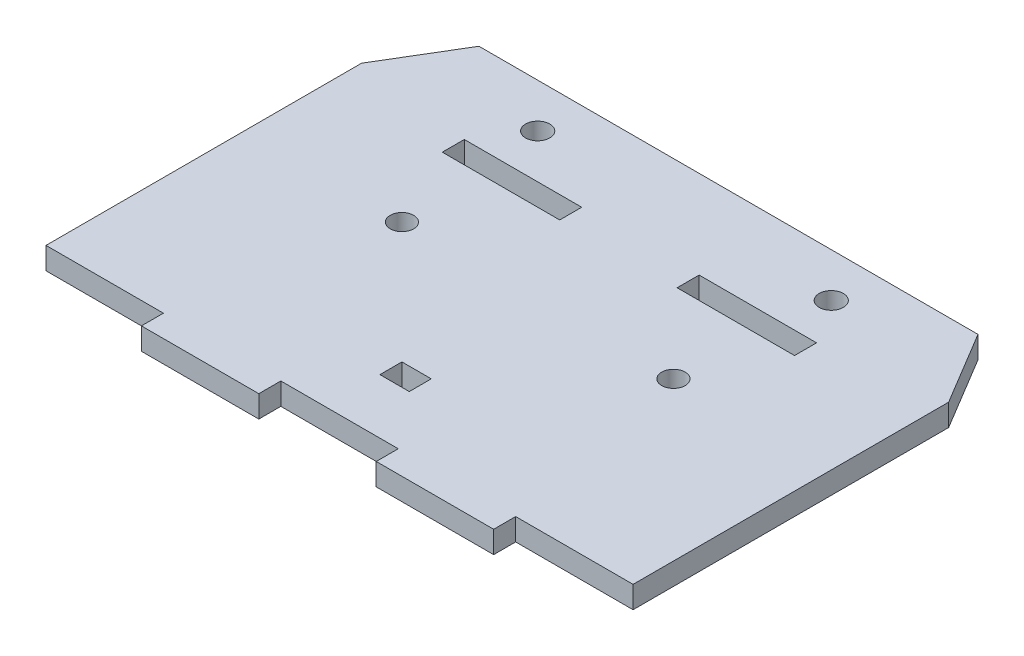
from build123d import *

# Parameters (mm, degrees)
SKETCH1_R           = 1.65
BOSS_EXTRUDE1_DEPTH = 3
SKETCH2_R           = 1.6
SKETCH2_W           = 4
SKETCH2_H           = 3
SKETCH2_W_2         = 16
CUT_EXTRUDE1_DEPTH  = 4


with BuildPart() as part:
    # Sketch1 → Boss-Extrude1 (new body)
    with BuildSketch(Plane(origin=(0, 0, 0), x_dir=(1, 0, 0), z_dir=(0, 1, 0))):
        Polygon((-40, 37), (-34, 47), (34, 47), (40, 37), (40, -6), (24, -6), (24, -9), (8, -9), (8, -6), (-8, -6), (-8, -9), (-24, -9), (-24, -6), (-40, -6), align=None)
        with Locations((-20, 41)):
            Circle(SKETCH1_R, mode=Mode.SUBTRACT)
        with Locations((20, 41.003103662)):
            Circle(SKETCH1_R, mode=Mode.SUBTRACT)
    extrude(amount=BOSS_EXTRUDE1_DEPTH)

    # Sketch2 → Cut-Extrude1 (cut, through all)
    with BuildSketch(Plane(origin=(0, 3, 0), x_dir=(1, 0, 0), z_dir=(0, 1, 0))):
        with Locations((-18.5, 21)):
            Circle(SKETCH2_R)
        with Locations((18.5, 21)):
            Circle(SKETCH2_R)
        with Locations((0, 3)):
            Rectangle(SKETCH2_W, SKETCH2_H)
        with Locations((-16, 33.5)):
            Rectangle(SKETCH2_W_2, SKETCH2_H)
        with Locations((16, 33.5)):
            Rectangle(SKETCH2_W_2, SKETCH2_H)
    extrude(amount=-CUT_EXTRUDE1_DEPTH, mode=Mode.SUBTRACT)


solid = part.part
